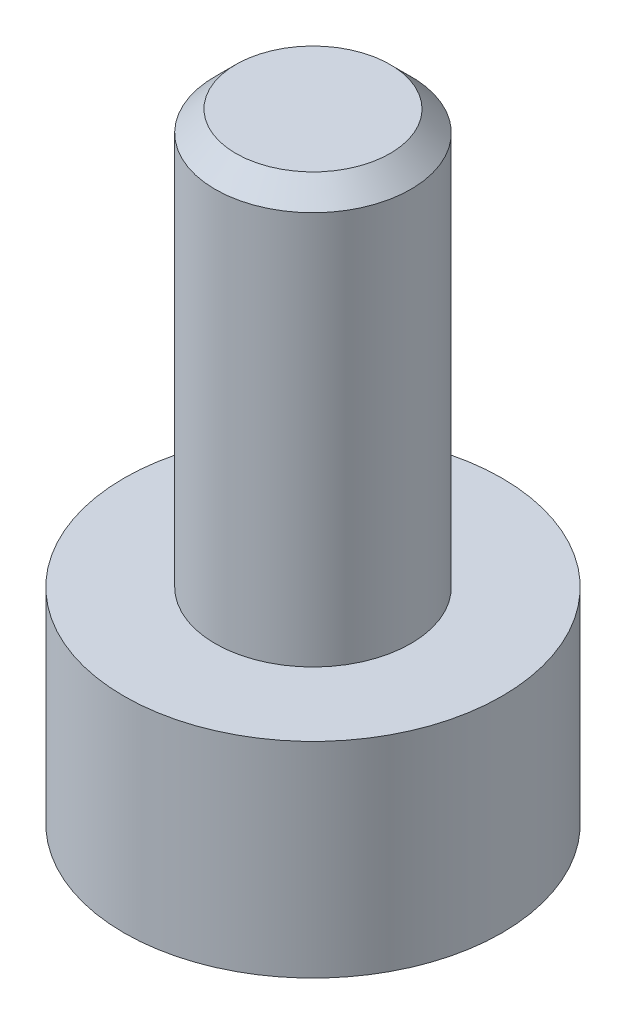
from build123d import *

# Parameters (mm, degrees)
SKETCH1_R           = 1.825
BOSS_EXTRUDE1_DEPTH = 1.98
SKETCH2_R           = 0.945
BOSS_EXTRUDE2_DEPTH = 4
CUT_EXTRUDE1_DEPTH  = 1
CHAMFER1_SIZE       = 0.2


with BuildPart() as part:
    # Sketch1 → Boss-Extrude1 (new body)
    with BuildSketch(Plane(origin=(0, 0, 0), x_dir=(1, 0, 0), z_dir=(0, 1, 0))):
        Circle(SKETCH1_R)
    extrude(amount=BOSS_EXTRUDE1_DEPTH)

    # Sketch2 → Boss-Extrude2 (add)
    with BuildSketch(Plane(origin=(0, 1.98, 0), x_dir=(1, 0, 0), z_dir=(0, 1, 0))):
        Circle(SKETCH2_R)
    extrude(amount=BOSS_EXTRUDE2_DEPTH)

    # Sketch3 → Cut-Extrude1 (cut)
    with BuildSketch(Plane.XZ):
        Polygon((0.458993464, -0.795), (0.917986928, 0), (0.458993464, 0.795), (-0.458993464, 0.795), (-0.917986928, 0), (-0.458993464, -0.795), align=None)
    extrude(amount=-CUT_EXTRUDE1_DEPTH, mode=Mode.SUBTRACT)

    # Chamfer1
    chamfer1_edges = [part.edges().sort_by_distance(p)[0] for p in [
        (-0.945, 5.98, 0),
    ]]
    chamfer(chamfer1_edges, length=CHAMFER1_SIZE)


solid = part.part
